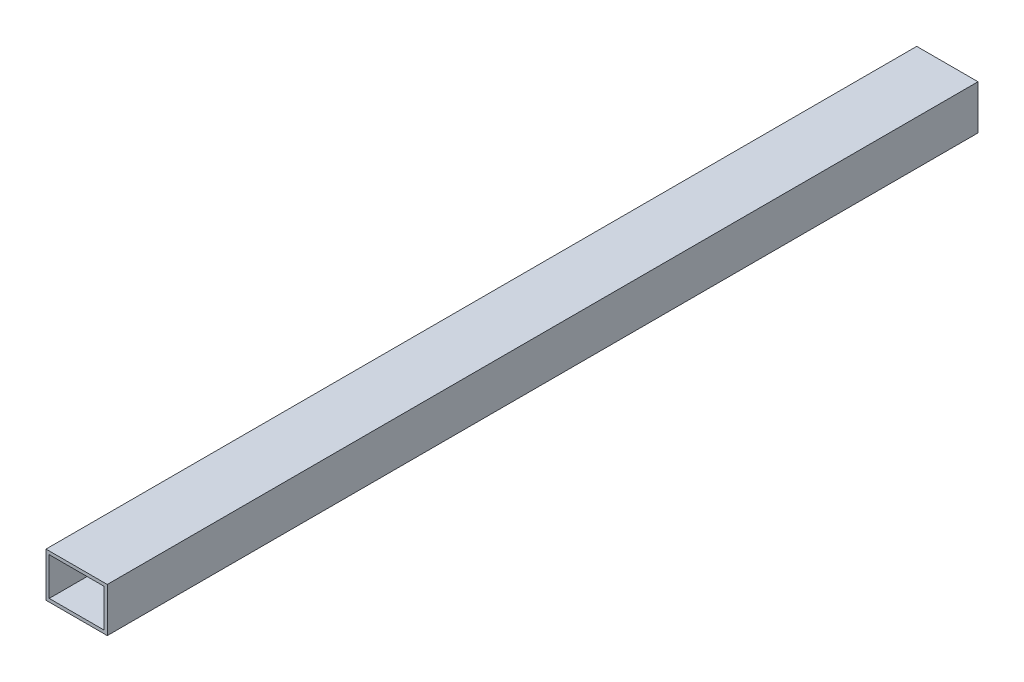
from build123d import *

# Parameters (mm, degrees)
SKETCH1_W           = 38
SKETCH1_H           = 27.5
SKETCH1_W_2         = 34
SKETCH1_H_2         = 23.5
BOSS_EXTRUDE1_DEPTH = 540


with BuildPart() as part:
    # Sketch1 → Boss-Extrude1 (new body)
    with BuildSketch(Plane.XY):
        with Locations((-15.906584243, 15.31701688)):
            Rectangle(SKETCH1_W, SKETCH1_H)
        with Locations((-15.906584243, 15.31701688)):
            Rectangle(SKETCH1_W_2, SKETCH1_H_2, mode=Mode.SUBTRACT)
    extrude(amount=BOSS_EXTRUDE1_DEPTH)


solid = part.part
